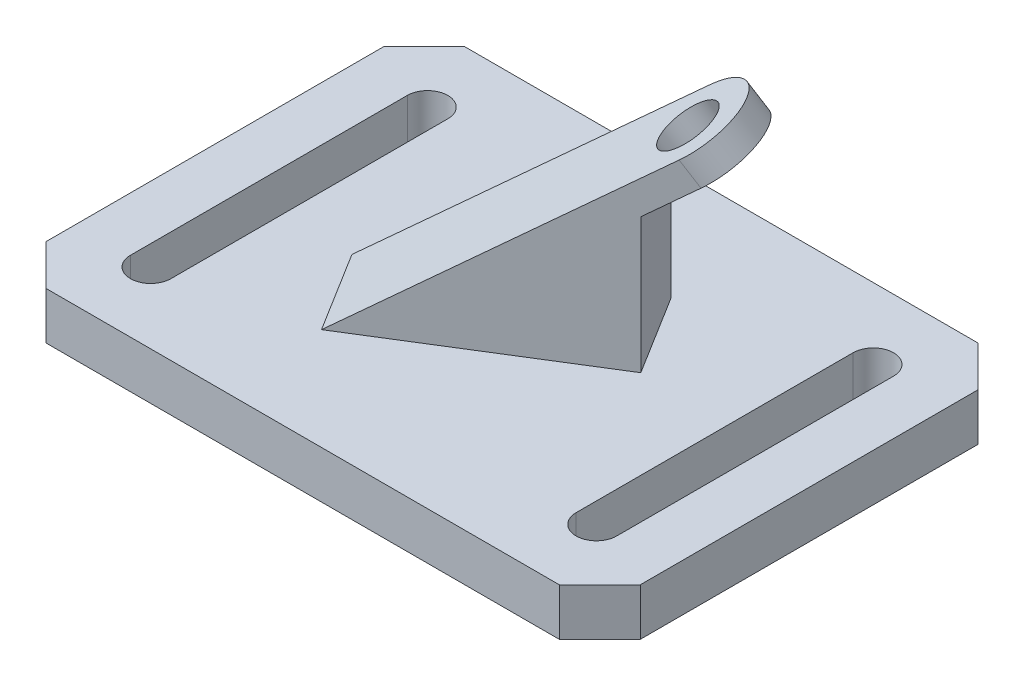
from build123d import *

# Parameters (mm, degrees)
BOSS_EXTRUDE1_DEPTH = 7
BOSS_EXTRUDE2_DEPTH = 7
CUT_EXTRUDE1_DEPTH  = 14
SKETCH7_R           = 4
CUT_EXTRUDE2_DEPTH  = 14


with BuildPart() as part:
    # Sketch1 → Boss-Extrude1 (new body)
    with BuildSketch(Plane(origin=(0, 0, 0), x_dir=(1, 0, 0), z_dir=(0, 1, 0))):
        Polygon((-44, 25), (-38, 31), (38, 31), (44, 25), (44, -25), (38, -31), (-38, -31), (-44, -25), align=None)
        with BuildLine():
            Line((-36, -20.5), (-36, 20.5))
            ThreePointArc((-36, 20.5), (-33, 23.5), (-30, 20.5))
            Line((-30, 20.5), (-30, -20.5))
            ThreePointArc((-30, -20.5), (-33, -23.5), (-36, -20.5))
        make_face(mode=Mode.SUBTRACT)
        with BuildLine():
            Line((30, -20.5), (30, 20.5))
            ThreePointArc((30, 20.5), (33, 23.5), (36, 20.5))
            Line((36, 20.5), (36, -20.5))
            ThreePointArc((36, -20.5), (33, -23.5), (30, -20.5))
        make_face(mode=Mode.SUBTRACT)
    extrude(amount=BOSS_EXTRUDE1_DEPTH)

    # Sketch4 → Boss-Extrude2 (add, symmetric)
    with BuildSketch(Plane(origin=(0, 0, 0), x_dir=(-0.849441251, 0, 0.527683201), z_dir=(-0.527683201, 0, -0.849441251))):
        Polygon((18.849066913, 7), (12.511788479, 7), (-15.483777963, 7), (-15.483777963, 27), (-27.619032879, 35.816778784), (-25.26789187, 39.052846762), align=None)
    extrude(amount=BOSS_EXTRUDE2_DEPTH, both=True)

    # Sketch6 → Cut-Extrude1 (cut)
    with BuildSketch(Plane(origin=(-8.359258135, 13.544823437, 5.192872478), x_dir=(0.866435488, 0.466201263, 0.178734239), z_dir=(-0.49928904, 0.809016994, 0.310164404))):
        with BuildLine():
            Line((30.156965838, 31.981920644), (24.604923104, 27.718726833))
            ThreePointArc((24.604923104, 27.718726833), (29.779470729, 29.107104419), (34.42015965, 26.42987791))
            Line((34.42015965, 26.42987791), (30.156965838, 31.981920644))
        make_face()
        with BuildLine():
            Line((38.683353462, 20.877835176), (34.42015965, 26.42987791))
            ThreePointArc((34.42015965, 26.42987791), (35.808537236, 21.255330285), (33.131310727, 16.614641364))
            Line((33.131310727, 16.614641364), (38.683353462, 20.877835176))
        make_face()
    extrude(amount=-CUT_EXTRUDE1_DEPTH, mode=Mode.SUBTRACT)

    # Sketch7 → Cut-Extrude2 (cut)
    with BuildSketch(Plane(origin=(-8.359258135, 13.544823437, 5.192872478), x_dir=(0.866435488, 0.466201263, 0.178734239), z_dir=(-0.49928904, 0.809016994, 0.310164404))):
        with Locations((28.191728041, 21.64731186)):
            Circle(SKETCH7_R)
    extrude(amount=-CUT_EXTRUDE2_DEPTH, mode=Mode.SUBTRACT)


solid = part.part
